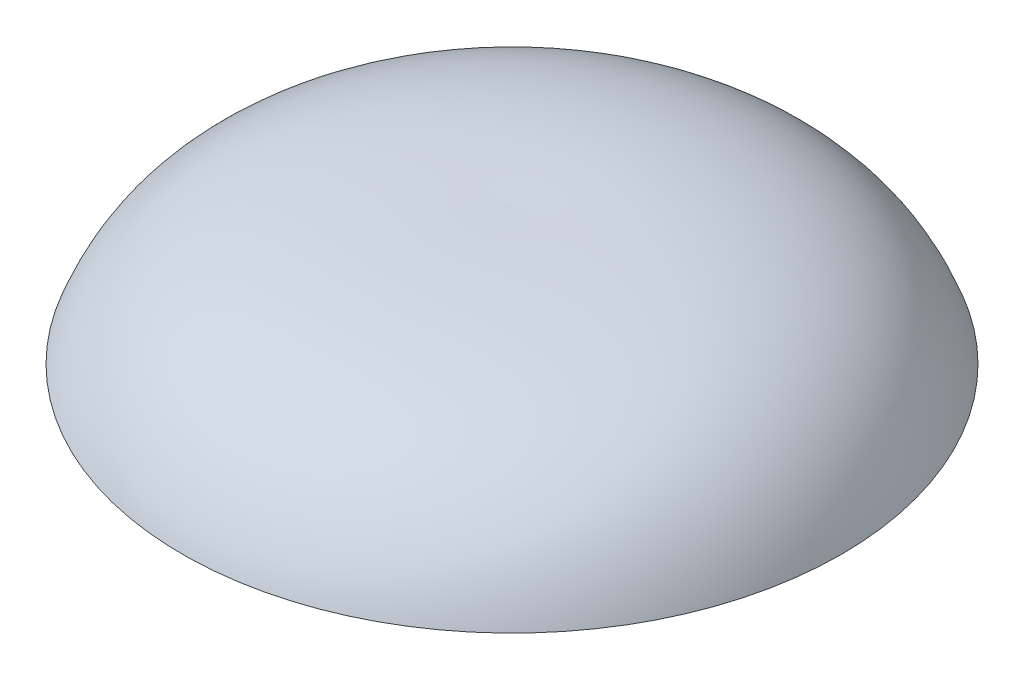
from build123d import *


with BuildPart() as part:
    # Sketch1 → Revolve1 (revolve)
    with BuildSketch(Plane.XY):
        with BuildLine():
            Line((0, 0), (12.7, 0))
            add(Edge.make_bspline(
                [(-2.54, 6.35), (5.737380688, 6.648428585), (10.816886931, 5.177353601), (12.7, 0)],
                knots=[0, 0, 0, 0, 1, 1, 1, 1], degree=3))
            Line((-2.54, 6.35), (-2.54, 0))
            Line((-2.54, 0), (-2.54, -2.54))
            Line((-2.54, -2.54), (0, -2.54))
            Line((0, -2.54), (0, 0))
        make_face()
    revolve(axis=Axis((-2.54, 6.35, 0), (0, 1, 0)))


solid = part.part
